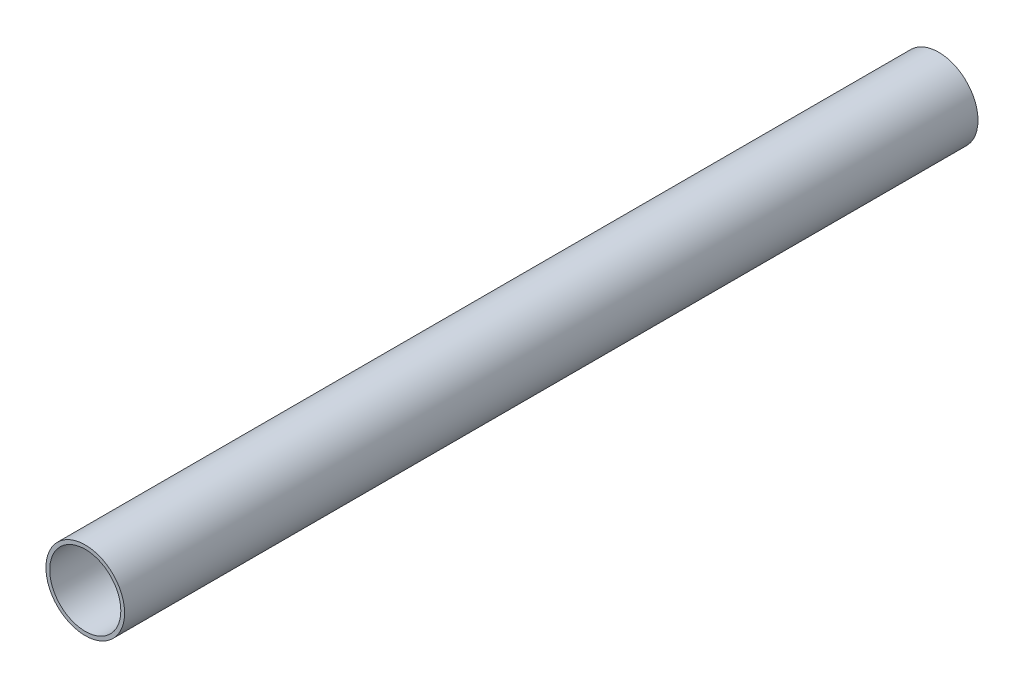
from build123d import *

# Parameters (mm, degrees)
SKETCH1_R           = 14.0462
SKETCH1_R_2         = 12.7
EXTRUDE_THIN1_DEPTH = 152.4


with BuildPart() as part:
    # Sketch1 → Extrude-Thin1 (new body, symmetric)
    with BuildSketch(Plane.XY):
        Circle(SKETCH1_R)
        Circle(SKETCH1_R_2, mode=Mode.SUBTRACT)
    extrude(amount=EXTRUDE_THIN1_DEPTH, both=True)


solid = part.part
